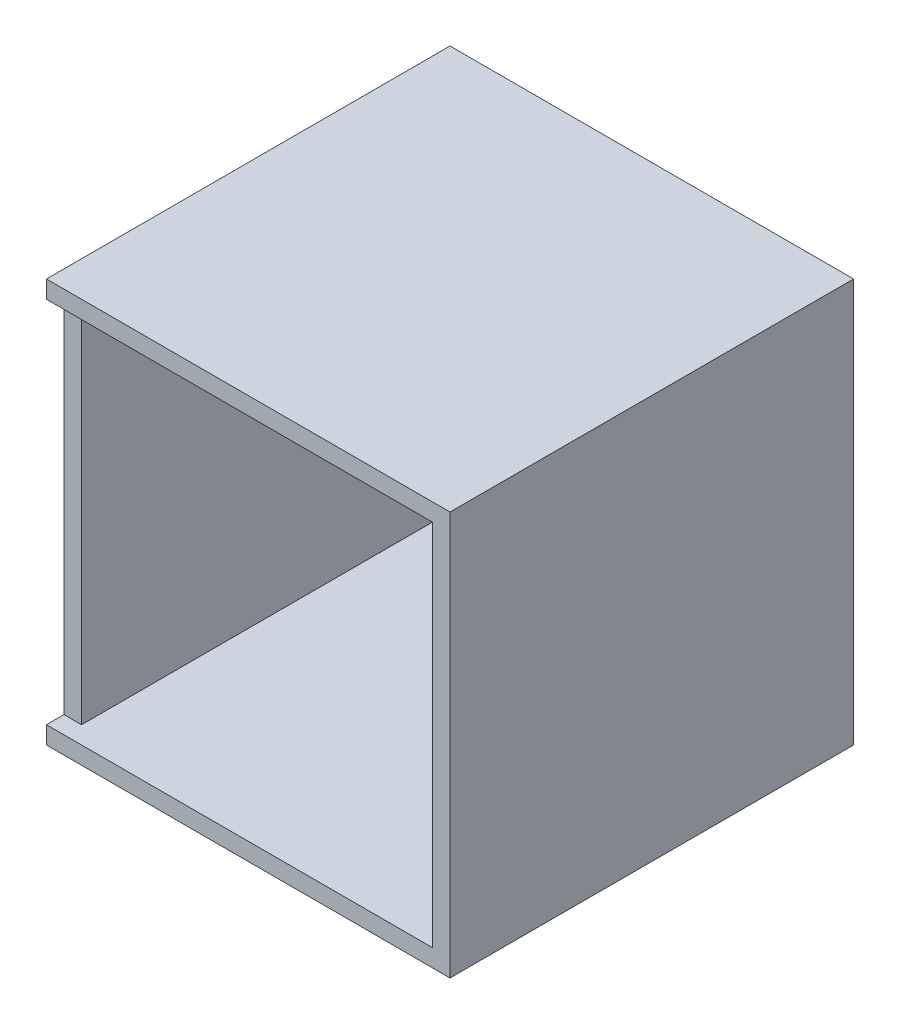
from build123d import *

# Parameters (mm, degrees)
SKETCH2_W           = 292.1
SKETCH2_H           = 292.1
BOSS_EXTRUDE1_DEPTH = 146.05
SHELL1_T            = -12.7
SKETCH3_W           = 44.121317042
SKETCH3_H           = 266.7
CUT_EXTRUDE1_DEPTH  = 12.7
SKETCH4_W           = 8.89
SKETCH4_H           = 10.922
CUT_EXTRUDE2_DEPTH  = 2.54


with BuildPart() as part:
    # Sketch2 → Boss-Extrude1 (new body, symmetric)
    with BuildSketch(Plane.XY):
        Rectangle(SKETCH2_W, SKETCH2_H)
    extrude(amount=BOSS_EXTRUDE1_DEPTH, both=True)

    # Shell1
    shell1_openings = [part.faces().sort_by_distance(p)[0] for p in [
        (0, 0, 146.05),
    ]]
    offset(amount=SHELL1_T, openings=shell1_openings, kind=Kind.INTERSECTION)

    # Sketch3 → Cut-Extrude1 (cut)
    with BuildSketch(Plane.XY.offset(146.05)):
        with Locations((-133.35, 0)):
            Rectangle(SKETCH3_W, SKETCH3_H)
    extrude(amount=-CUT_EXTRUDE1_DEPTH, mode=Mode.SUBTRACT)

    # Sketch4 → Cut-Extrude2 (cut)
    with BuildSketch(Plane(origin=(0, 0, -146.05), x_dir=(-1, 0, 0), z_dir=(0, 0, -1))):
        with Locations((-90.805, -89.789)):
            Rectangle(SKETCH4_W, SKETCH4_H)
    extrude(amount=-CUT_EXTRUDE2_DEPTH, mode=Mode.SUBTRACT)


solid = part.part
